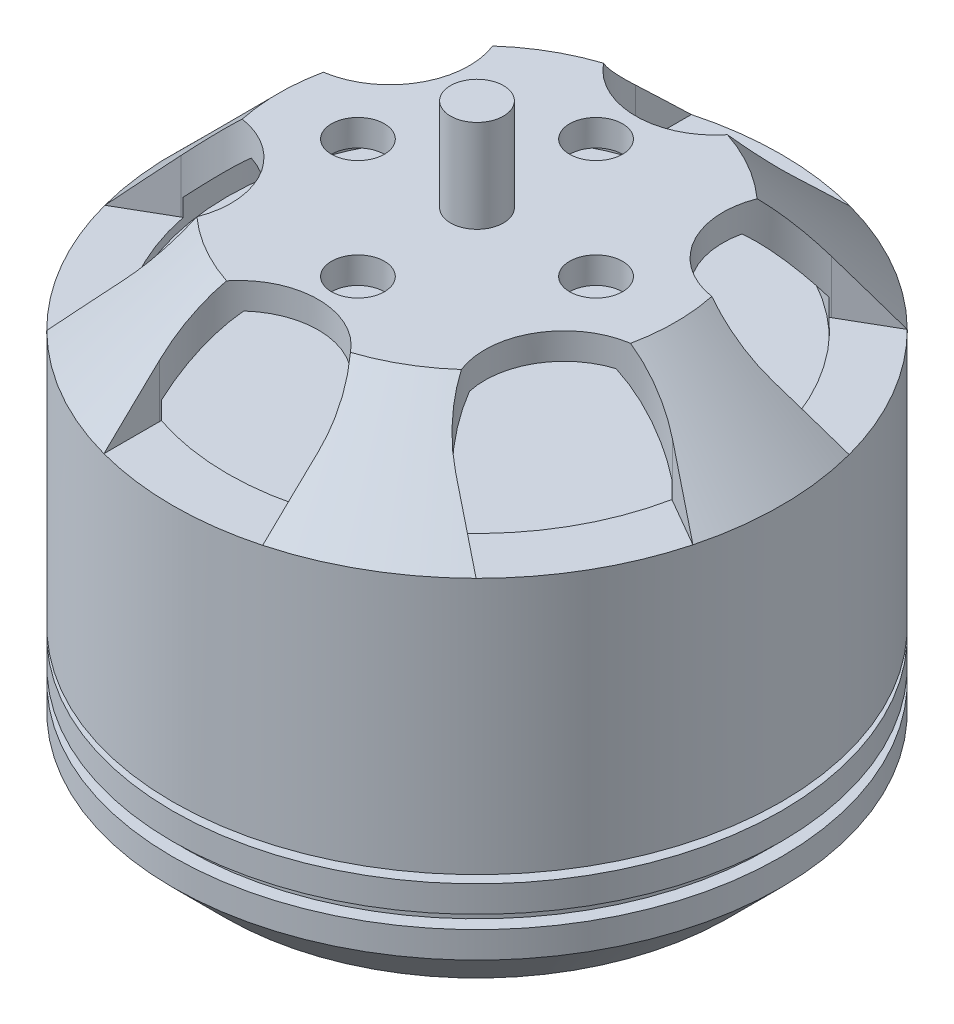
from build123d import *

# Parameters (mm, degrees)
SKETCH2_R          = 1
CUT_EXTRUDE1_DEPTH = 4
SKETCH3_R          = 1
CUT_EXTRUDE2_DEPTH = 3


with BuildPart() as part:
    # Sketch1 → Revolve1 (revolve)
    with BuildSketch(Plane.XY):
        Polygon((0, 20.601977979), (0, 0), (0, -3.198022021), (1, -3.198022021), (1, -1.398022021), (9.5, -1.398022021), (11.5, 0.601977979), (11.5, 1.601977979), (11, 1.601977979), (11, 2.101977979), (11.5, 2.101977979), (11.5, 3.101977979), (9.5, 3.101977979), (9.5, 3.401977979), (11.5, 3.401977979), (11.5, 13.101977979), (7.5, 17.101977979), (1, 17.101977979), (1, 20.601977979), align=None)
        Polygon((2, 16.101977979), (7.085786438, 16.101977979), (9.423024171, 13.764740246), (9.423024171, 12.764740246), (1, 12.764740246), (1, 15.101977979), (2, 15.101977979), align=None, mode=Mode.SUBTRACT)
    revolve(axis=Axis((0, 20.601977979, 0), (0, -1, 0)))

    # Sketch2 → Cut-Extrude1 (cut)
    with BuildSketch(Plane(origin=(0, 17.101977979, 0), x_dir=(1, 0, 0), z_dir=(0, 1, 0))):
        with Locations((0, -4.5)):
            Circle(SKETCH2_R)
        with Locations((-4.5, 0)):
            Circle(SKETCH2_R)
        with Locations((0, 4.5)):
            Circle(SKETCH2_R)
        with Locations((4.5, 0)):
            Circle(SKETCH2_R)
        with BuildLine():
            Line((-3, 9), (-3, 16.77943101))
            Line((-3, 16.77943101), (3, 16.77943101))
            Line((3, 16.77943101), (3, 9))
            ThreePointArc((3, 9), (0, 6), (-3, 9))
        make_face()
        with BuildLine():
            Line((6.294228634, 7.098076211), (13.031413516, 10.987791717))
            Line((13.031413516, 10.987791717), (16.031413516, 5.791639294))
            Line((16.031413516, 5.791639294), (9.294228634, 1.901923789))
            ThreePointArc((9.294228634, 1.901923789), (5.196152423, 3), (6.294228634, 7.098076211))
        make_face()
        with BuildLine():
            Line((9.294228634, -1.901923789), (16.031413516, -5.791639294))
            Line((16.031413516, -5.791639294), (13.031413516, -10.987791717))
            Line((13.031413516, -10.987791717), (6.294228634, -7.098076211))
            ThreePointArc((6.294228634, -7.098076211), (5.196152423, -3), (9.294228634, -1.901923789))
        make_face()
        with BuildLine():
            Line((3, -9), (3, -16.77943101))
            Line((3, -16.77943101), (-3, -16.77943101))
            Line((-3, -16.77943101), (-3, -9))
            ThreePointArc((-3, -9), (0, -6), (3, -9))
        make_face()
        with BuildLine():
            Line((-6.294228634, -7.098076211), (-13.031413516, -10.987791717))
            Line((-13.031413516, -10.987791717), (-16.031413516, -5.791639294))
            Line((-16.031413516, -5.791639294), (-9.294228634, -1.901923789))
            ThreePointArc((-9.294228634, -1.901923789), (-5.196152423, -3), (-6.294228634, -7.098076211))
        make_face()
        with BuildLine():
            Line((-9.294228634, 1.901923789), (-16.031413516, 5.791639294))
            Line((-16.031413516, 5.791639294), (-13.031413516, 10.987791717))
            Line((-13.031413516, 10.987791717), (-6.294228634, 7.098076211))
            ThreePointArc((-6.294228634, 7.098076211), (-5.196152423, 3), (-9.294228634, 1.901923789))
        make_face()
    extrude(amount=-CUT_EXTRUDE1_DEPTH, mode=Mode.SUBTRACT)

    # Sketch3 → Cut-Extrude2 (cut)
    with BuildSketch(Plane.XZ.offset(1.398022021)):
        with Locations((0, 6)):
            Circle(SKETCH3_R)
        with Locations((0, -6)):
            Circle(SKETCH3_R)
        with Locations((-8, 0)):
            Circle(SKETCH3_R)
        with Locations((8, 0)):
            Circle(SKETCH3_R)
    extrude(amount=-CUT_EXTRUDE2_DEPTH, mode=Mode.SUBTRACT)


solid = part.part
